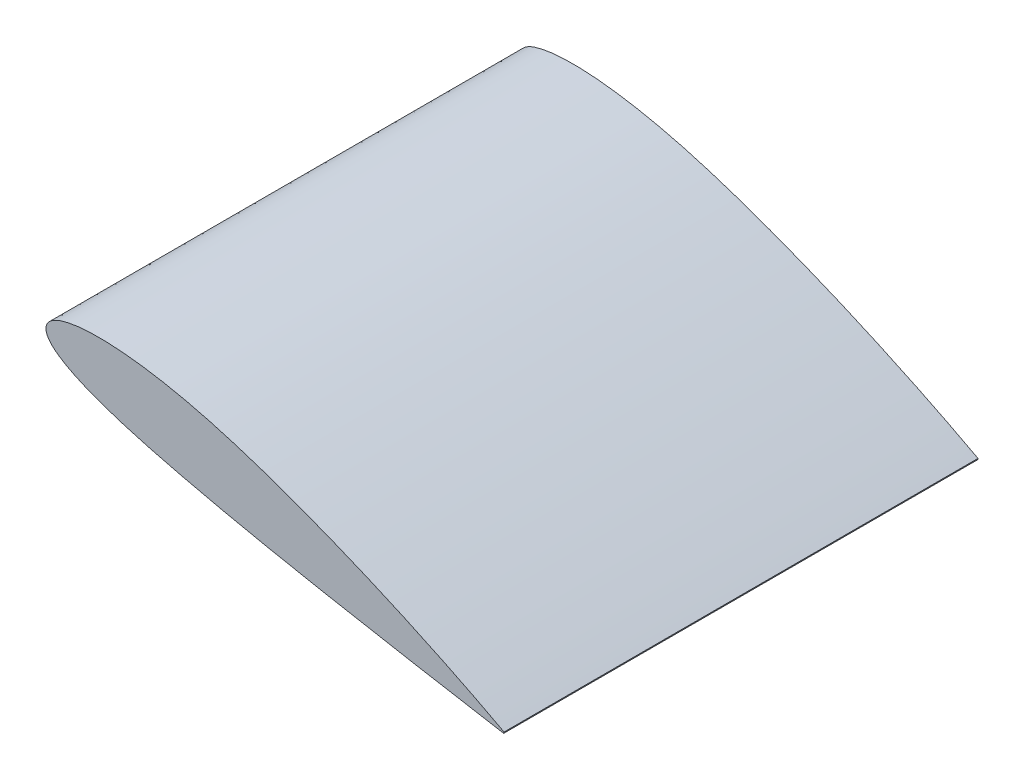
from build123d import *

# Parameters (mm, degrees)
DODANIE_WYCI_GNI_CIE1_DEPTH = 500


with BuildPart() as part:
    # Szkic1 → Dodanie-wyciągnięcie1 (new body)
    with BuildSketch(Plane.XY):
        with BuildLine():
            Line((500, -0.735), (500.380463996, 0.684910965))
            add(Edge.make_bspline(
                [(500.380463996, 0.684910965), (499.987761896, 0.899476742), (498.379520002, 1.778192879), (494.724795459, 3.69339889), (488.668576118, 6.894733113), (480.253931872, 11.269378601), (469.572425637, 16.75450222), (451.124700389, 26.035093323), (423.330265585, 39.547917955), (385.020236461, 57.221142732), (349.324231508, 72.668447998), (318.470794534, 85.26407028), (294.236154178, 94.739860643), (269.581372848, 103.882526411), (244.769860079, 112.562781079), (219.993165082, 120.660650275), (195.478965564, 127.907059723), (171.487528336, 134.109047715), (148.380181626, 139.184804352), (126.430423416, 143.078422896), (105.905312395, 145.788264467), (87.050640336, 147.299335084), (70.098861443, 147.683325605), (55.251572494, 146.986744576), (42.673442814, 145.31235672), (32.472209123, 142.737894507), (24.704267022, 139.324272409), (19.307425265, 134.987872263), (16.710094113, 129.467983343), (17.409011146, 123.419135392), (21.076284182, 117.590462904), (27.212420899, 111.851854762), (35.791202383, 106.038418863), (46.76508357, 100.176074018), (60.035595637, 94.305073489), (75.457655682, 88.457417989), (92.871043629, 82.676997129), (112.084328552, 76.980504071), (132.888183707, 71.363838458), (155.060073334, 65.835193864), (178.357035663, 60.366276311), (202.597404222, 54.914918299), (227.527923514, 49.506080863), (252.906393243, 44.294652952), (278.366510634, 39.269195212), (311.620345136, 32.87510139), (351.272117201, 25.518036322), (389.202855163, 18.63102267), (422.409279568, 12.706906639), (445.437633812, 8.634889026), (465.708003926, 5.121994052), (477.513007878, 3.08355855), (486.845699898, 1.494280334), (493.590102545, 0.344727075), (497.689473289, -0.333235063), (499.52680728, -0.652719089), (500, -0.735)],
                knots=[0, 0, 0, 0, 0.001308371, 0.005358201, 0.012063409, 0.021337301, 0.033086619, 0.047170643, 0.081714352, 0.123442225, 0.17051687, 0.195424313, 0.220875125, 0.246594093, 0.272301831, 0.297725323, 0.322799376, 0.347028843, 0.370161527, 0.391953614, 0.412187726, 0.430670139, 0.447230521, 0.461731545, 0.474085212, 0.484275747, 0.492391839, 0.498749378, 0.504100298, 0.509453028, 0.515789797, 0.523837666, 0.533884867, 0.546005347, 0.560170802, 0.576284399, 0.594211191, 0.613803379, 0.634869304, 0.657209967, 0.680611019, 0.704834652, 0.729852897, 0.755196951, 0.780582678, 0.805728554, 0.854204497, 0.898493683, 0.918442716, 0.95282566, 0.966867904, 0.978592199, 0.987851654, 0.994547444, 0.998595732, 1, 1, 1, 1], degree=3))
        make_face()
    extrude(amount=DODANIE_WYCI_GNI_CIE1_DEPTH)


solid = part.part
